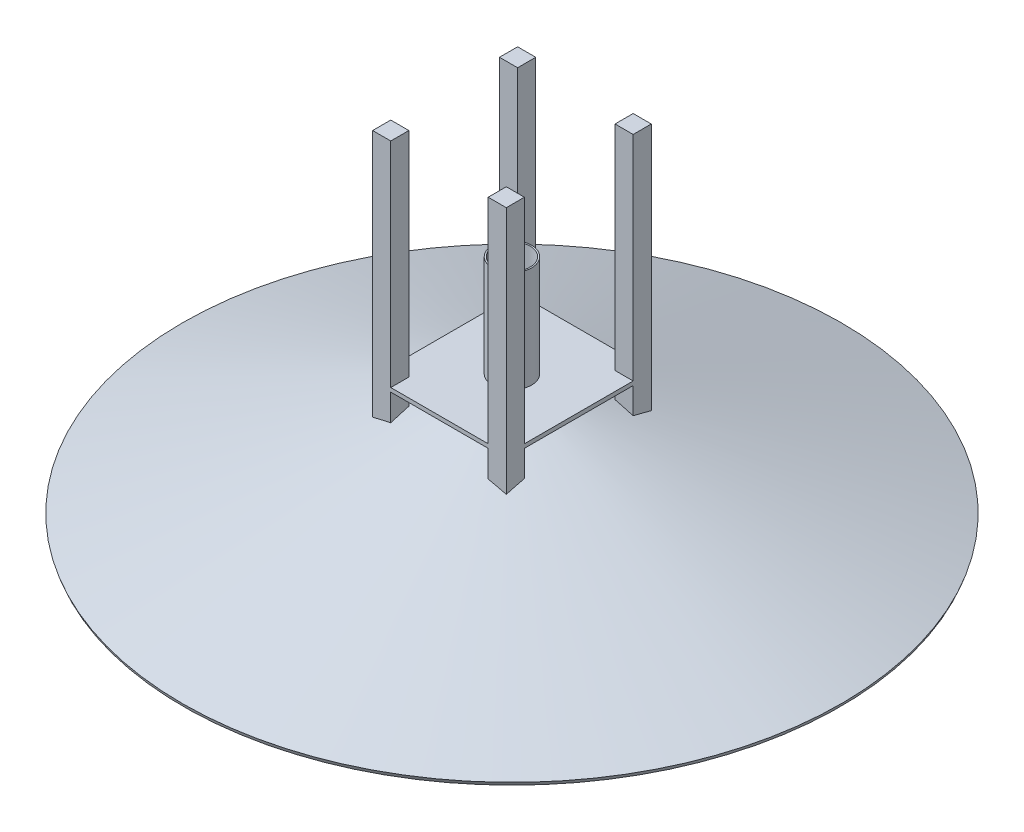
from build123d import *

# Parameters (mm, degrees)
BOSS_EXTRUDE2_DEPTH  = 11.1125
SKETCH1_11_W         = 50.8
SKETCH1_11_H         = 50.8
BOSS_EXTRUDE3_DEPTH  = 609.6
SKETCH1_12_W         = 50.8
SKETCH1_12_H         = 50.8
BOSS_EXTRUDE4_DEPTH  = 609.6
SKETCH1_13_W         = 50.8
SKETCH1_13_H         = 50.8
BOSS_EXTRUDE5_DEPTH  = 609.6
SKETCH1_14_W         = 50.8
SKETCH1_14_H         = 50.8
BOSS_EXTRUDE6_DEPTH  = 609.6
SKETCH4_R            = 50.8
CUT_EXTRUDE2_DEPTH   = 12.1125
SKETCH5_W            = 165.1
SKETCH5_H            = 152.4
SKETCH5_W_2          = 139.7
SKETCH5_H_2          = 127
BOSS_EXTRUDE8_DEPTH  = 17.78
SKETCH13_W           = 50.8
SKETCH13_H           = 50.8
BOSS_EXTRUDE9_DEPTH  = 381
SKETCH14_R           = 55
SKETCH14_R_2         = 50.90263009
BOSS_EXTRUDE10_DEPTH = 284.5


with BuildPart() as part:
    # Sketch1 → Boss-Extrude2 (new body)
    with BuildSketch(Plane(origin=(0, 0, 0), x_dir=(1, 0, 0), z_dir=(0, 1, 0))):
        Polygon((-136.525, 152.4), (-187.325, 152.4), (-187.325, -203.2), (187.325, -203.2), (187.325, 203.2), (-136.525, 203.2), align=None)
    extrude(amount=BOSS_EXTRUDE2_DEPTH)

    # Sketch1_11 → Boss-Extrude3 (add)
    with BuildSketch(Plane(origin=(0, 0, 0), x_dir=(1, 0, 0), z_dir=(0, 1, 0))):
        with Locations((-161.925, 177.8)):
            Rectangle(SKETCH1_11_W, SKETCH1_11_H)
    extrude(amount=BOSS_EXTRUDE3_DEPTH)

    # Sketch1_12 → Boss-Extrude4 (add)
    with BuildSketch(Plane(origin=(0, 0, 0), x_dir=(1, 0, 0), z_dir=(0, 1, 0))):
        with Locations((-161.925, -177.8)):
            Rectangle(SKETCH1_12_W, SKETCH1_12_H)
    extrude(amount=BOSS_EXTRUDE4_DEPTH)

    # Sketch1_13 → Boss-Extrude5 (add)
    with BuildSketch(Plane(origin=(0, 0, 0), x_dir=(1, 0, 0), z_dir=(0, 1, 0))):
        with Locations((161.925, 177.8)):
            Rectangle(SKETCH1_13_W, SKETCH1_13_H)
    extrude(amount=BOSS_EXTRUDE5_DEPTH)

    # Sketch1_14 → Boss-Extrude6 (add)
    with BuildSketch(Plane(origin=(0, 0, 0), x_dir=(1, 0, 0), z_dir=(0, 1, 0))):
        with Locations((161.925, -177.8)):
            Rectangle(SKETCH1_14_W, SKETCH1_14_H)
    extrude(amount=BOSS_EXTRUDE6_DEPTH)

    # Sketch4 → Cut-Extrude2 (cut, through all)
    with BuildSketch(Plane(origin=(0, 11.1125, 0), x_dir=(1, 0, 0), z_dir=(0, 1, 0))):
        Circle(SKETCH4_R)
    extrude(amount=-CUT_EXTRUDE2_DEPTH, mode=Mode.SUBTRACT)

    # Sketch5 → Boss-Extrude8 (add)
    with BuildSketch(Plane.XZ):
        Rectangle(SKETCH5_W, SKETCH5_H)
        Rectangle(SKETCH5_W_2, SKETCH5_H_2, mode=Mode.SUBTRACT)
    extrude(amount=BOSS_EXTRUDE8_DEPTH)

    # Sketch12 → Revolve-Thin1 (revolve)
    with BuildSketch(Plane.XY):
        Polygon((-63.5, -17.78), (-920.495660607, -336.662106272), (-923.982997727, -327.289887762), (-66.98733712, -8.407781489), align=None)
    revolve(axis=Axis((0, -17.78, 0), (0, -1, 0)))

    # Sketch13 → Boss-Extrude9 (add)
    with BuildSketch(Plane.XZ):
        with Locations((-161.925, 177.8)):
            Rectangle(SKETCH13_W, SKETCH13_H)
        with Locations((161.925, 177.8)):
            Rectangle(SKETCH13_W, SKETCH13_H)
        with Locations((161.925, -177.8)):
            Rectangle(SKETCH13_W, SKETCH13_H)
        with Locations((-161.925, -177.8)):
            Rectangle(SKETCH13_W, SKETCH13_H)
    extrude(amount=BOSS_EXTRUDE9_DEPTH)

    # Sketch14 → Boss-Extrude10 (add)
    with BuildSketch(Plane(origin=(0, 11.1125, 0), x_dir=(1, 0, 0), z_dir=(0, 1, 0))):
        Circle(SKETCH14_R)
        Circle(SKETCH14_R_2, mode=Mode.SUBTRACT)
    extrude(amount=BOSS_EXTRUDE10_DEPTH)


solid = part.part
